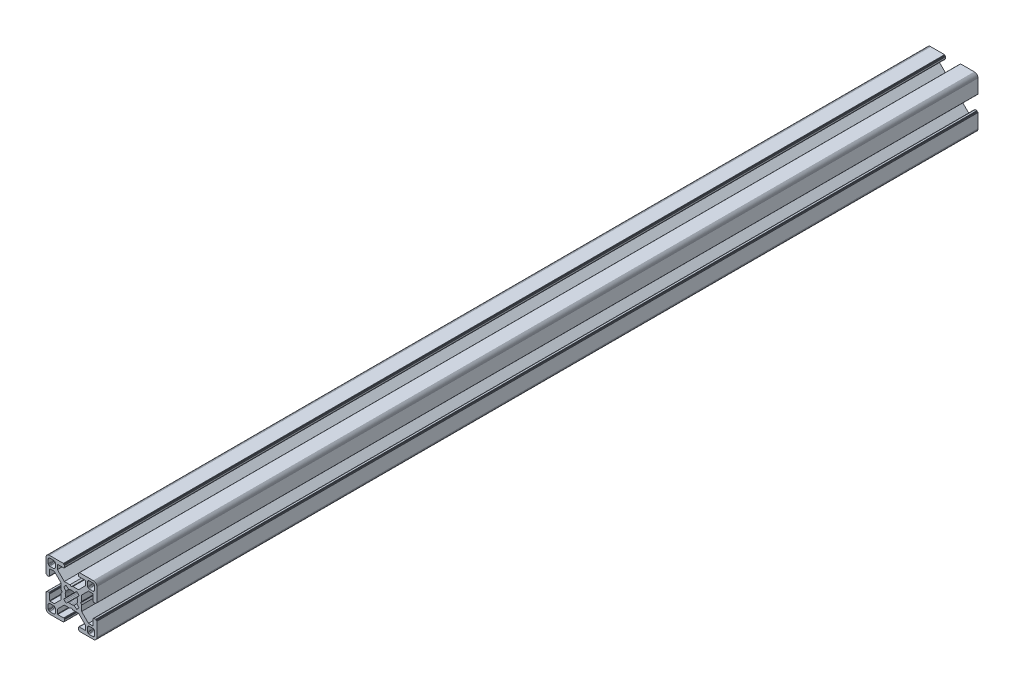
from build123d import *

# Parameters (mm, degrees)
BOSS_EXTRUDE1_DEPTH = 520


with BuildPart() as part:
    # Sketch1 → Boss-Extrude1 (new body)
    with BuildSketch(Plane.XY):
        Polygon((28.34729664, 29.969613999), (28.000000864, 29.999999329), (19.750000909, 29.999999329), (19.715268165, 29.996961355), (19.681595266, 29.987938702), (19.649999216, 29.973205179), (19.621443003, 29.953207821), (19.596790895, 29.928557575), (19.576793537, 29.899999499), (19.562061876, 29.868405312), (19.55303736, 29.834728688), (19.549999386, 29.799999669), (19.549999386, 29.699999839), (19.546961412, 29.665268958), (19.537936896, 29.631596059), (19.523203373, 29.599998146), (19.503207877, 29.571441934), (19.478557631, 29.546789825), (19.449999556, 29.526794329), (19.418403506, 29.512060806), (19.384728745, 29.503038153), (19.349999726, 29.500000179), (19.249999896, 29.500000179), (19.215267517, 29.496958527), (19.181592755, 29.487935874), (19.149996706, 29.47320235), (19.12143863, 29.453206855), (19.096788384, 29.428554746), (19.076791026, 29.399996671), (19.062057503, 29.368402484), (19.05303485, 29.334725859), (19.049996876, 29.299998703), (19.049996876, 28.39999837), (19.059110798, 28.29580945), (19.08618062, 28.194785165), (19.13038119, 28.099997016), (19.190369539, 28.014324653), (19.264324002, 27.94037019), (19.349996366, 27.88038184), (19.444784515, 27.836181271), (19.545806937, 27.809111449), (19.650010894, 27.799984574), (23.050010706, 27.799984574), (23.084741588, 27.7969466), (23.118414487, 27.787923946), (23.150012399, 27.773190423), (23.178568612, 27.753193065), (23.203220721, 27.728542819), (23.223218079, 27.699984744), (23.237949739, 27.668386831), (23.246974255, 27.634713932), (23.25001142, 27.59998608), (23.25001142, 25.049987618), (19.204474482, 20.999982084), (15.900007876, 20.999982084), (15.000008474, 20.48483404), (14.10000814, 20.999982084), (10.795543398, 20.999982084), (7.997342887, 23.801274731), (6.750011387, 25.049984589), (6.750011387, 27.599983051), (6.753049362, 27.634713932), (6.762072946, 27.668386831), (6.776805538, 27.699984744), (6.796801965, 27.728542819), (6.821454073, 27.753193065), (6.850011218, 27.773190423), (6.881607267, 27.787923946), (6.915282029, 27.7969466), (6.950011048, 27.799984574), (10.350011791, 27.799984574), (10.45420071, 27.809098497), (10.555223133, 27.836168318), (10.650011282, 27.880368888), (10.735683645, 27.940357238), (10.809638108, 28.014311701), (10.869626458, 28.099984064), (10.913827027, 28.194772213), (10.940895918, 28.295796498), (10.950010772, 28.399985417), (10.950010772, 29.299985751), (10.946974575, 29.334739239), (10.93795065, 29.368415522), (10.923215933, 29.400009153), (10.903218427, 29.428566473), (10.878566319, 29.45321765), (10.849999264, 29.473204166), (10.818403214, 29.487937689), (10.784728453, 29.496960342), (10.749999434, 29.500000179), (10.649999604, 29.500000179), (10.615270585, 29.503038153), (10.581595823, 29.512060806), (10.549999774, 29.526794329), (10.521441698, 29.546789825), (10.496791452, 29.571441934), (10.476795025, 29.599998146), (10.462061502, 29.631596059), (10.453037918, 29.665268958), (10.449999943, 29.699999839), (10.449999943, 29.799999669), (10.446961969, 29.834728688), (10.437938385, 29.868405312), (10.423205793, 29.899999499), (10.403208435, 29.928557575), (10.378557257, 29.953207821), (10.350000113, 29.973205179), (10.318404064, 29.987938702), (10.284729302, 29.996961355), (10.250000283, 29.999999329), (1.999999397, 29.999999329), (1.652702689, 29.969613999), (1.315958682, 29.879383743), (0.999999233, 29.732050374), (0.714424066, 29.532089829), (0.467910431, 29.285576195), (0.267948955, 28.999999166), (0.120614655, 28.684040532), (0.030384399, 28.34729664), (0, 28.000000864), (0, 19.750000909), (0.003037974, 19.715268165), (0.012061559, 19.681595266), (0.026795082, 19.649999216), (0.046790577, 19.621441141), (0.071442686, 19.596789032), (0.09999983, 19.576793537), (0.13159588, 19.562060013), (0.165270641, 19.55303736), (0.19999966, 19.549999386), (0.299999461, 19.549999386), (0.334728509, 19.546959549), (0.368403242, 19.537936896), (0.399999321, 19.523203373), (0.428556465, 19.503207877), (0.453208573, 19.478555769), (0.473204069, 19.449997693), (0.487937592, 19.418403506), (0.496961176, 19.384728745), (0.499999151, 19.349999726), (0.499999151, 19.249998033), (0.503038056, 19.215269014), (0.512060709, 19.181594253), (0.526794232, 19.150000066), (0.546790194, 19.121441524), (0.571441837, 19.096789882), (0.60000029, 19.076794925), (0.631595686, 19.062061999), (0.665270619, 19.053039982), (0.700000626, 19.050000801), (1.60000096, 19.050000801), (1.704189879, 19.059116587), (1.805213233, 19.086186409), (1.90000045, 19.130385115), (1.985673745, 19.190375328), (2.059627277, 19.264327928), (2.119616325, 19.350002154), (2.163816196, 19.444788441), (2.190886018, 19.545812726), (2.200000872, 19.650001645), (2.200000872, 23.050001457), (2.203039777, 23.084732338), (2.212062431, 23.118405237), (2.226795954, 23.15000315), (2.246792381, 23.178559362), (2.271443558, 23.203211471), (2.300000702, 23.223206967), (2.331596752, 23.23794049), (2.365271513, 23.246965006), (2.400001464, 23.250001117), (4.950000857, 23.250001117), (7.997332093, 20.202670812), (8.995535423, 19.204467788), (8.995535423, 15.900001182), (9.515148227, 15.00000178), (8.995535423, 14.100002378), (8.995535423, 10.795536704), (4.950000857, 6.750002138), (2.400001464, 6.750002138), (2.365271513, 6.753040112), (2.331596752, 6.762063697), (2.300000702, 6.77679722), (2.271443558, 6.796793647), (2.246792381, 6.821444824), (2.226795954, 6.850001968), (2.212062431, 6.881598018), (2.203039777, 6.915272779), (2.200000872, 6.950002729), (2.200000872, 10.350002542), (2.190896812, 10.454174265), (2.16382699, 10.555197618), (2.119627119, 10.649984836), (2.059638071, 10.735658131), (1.985684539, 10.809611663), (1.900011244, 10.869600944), (1.805224027, 10.913800582), (1.704200673, 10.940870404), (1.600011754, 10.949986189), (0.70001142, 10.949986189), (0.665281355, 10.946948596), (0.631606253, 10.937926283), (0.600010578, 10.923193954), (0.571451747, 10.903199537), (0.546799638, 10.87854836), (0.526794232, 10.850000195), (0.512060709, 10.818404146), (0.503038056, 10.784730315), (0.499999151, 10.750000365), (0.499999151, 10.650000535), (0.496961176, 10.615270585), (0.487937592, 10.581596754), (0.473204069, 10.550000705), (0.453208573, 10.521443561), (0.428556465, 10.496791452), (0.399999321, 10.476795956), (0.368403242, 10.462062433), (0.334728509, 10.453038849), (0.299999461, 10.449999943), (0.19999966, 10.449999943), (0.165270641, 10.446961969), (0.13159588, 10.437939316), (0.09999983, 10.423205793), (0.071442686, 10.403209366), (0.046790577, 10.378558189), (0.026795082, 10.350000113), (0.012061559, 10.318404064), (0.003037974, 10.284729302), (0, 10.250000283), (0, 1.999999397), (0.030384399, 1.652702689), (0.120614655, 1.315958682), (0.267948955, 0.999999233), (0.467910431, 0.714424066), (0.714424066, 0.467910431), (0.999999233, 0.267948955), (1.315958682, 0.120614655), (1.652702689, 0.030384399), (1.999999397, 0), (10.250000283, 0), (10.284729302, 0.003037974), (10.318404064, 0.012061559), (10.350000113, 0.026795082), (10.378557257, 0.046790577), (10.403208435, 0.071442686), (10.423205793, 0.09999983), (10.437938385, 0.13159588), (10.446961969, 0.165270641), (10.449999943, 0.19999966), (10.449999943, 0.300000422), (10.453037918, 0.334729441), (10.462061502, 0.368404202), (10.476795025, 0.400000252), (10.496791452, 0.428557396), (10.521441698, 0.453208573), (10.549999774, 0.473205), (10.581595823, 0.487938523), (10.615270585, 0.496961176), (10.649999604, 0.500000082), (10.749999434, 0.500000082), (10.784728453, 0.503038056), (10.818403214, 0.512060709), (10.849999264, 0.526794232), (10.878547894, 0.546800104), (10.903198606, 0.571451747), (10.923194493, 0.6000102), (10.93792742, 0.631606528), (10.946949437, 0.66528146), (10.950010772, 0.699984975), (10.950010772, 1.599985308), (10.940895918, 1.704174228), (10.913827027, 1.805197581), (10.869626458, 1.89998573), (10.809638108, 1.985658094), (10.735683645, 2.059612557), (10.650011282, 2.119600674), (10.555223133, 2.163801476), (10.45420071, 2.190870367), (10.350011791, 2.199985221), (6.950011048, 2.199985221), (6.915282029, 2.203024126), (6.881607267, 2.212046779), (6.850011218, 2.226780302), (6.821454073, 2.246776729), (6.796801965, 2.271427907), (6.776805538, 2.299985982), (6.762072946, 2.331582032), (6.753049362, 2.365256793), (6.750011387, 2.399985812), (6.750011387, 4.949985206), (9.787457566, 7.990785077), (10.795545277, 8.999985833), (14.100010019, 8.999985833), (15.000010353, 9.515133877), (15.900009756, 8.999985833), (19.204476361, 8.999985833), (20.21256413, 7.990786065), (23.25001142, 4.949988235), (23.25001142, 2.399988841), (23.246974255, 2.365256793), (23.237949739, 2.331582032), (23.223218079, 2.299985982), (23.203220721, 2.271427907), (23.178568612, 2.246776729), (23.150012399, 2.226780302), (23.118414487, 2.212046779), (23.084741588, 2.203024126), (23.050010706, 2.199985221), (19.650010894, 2.199985221), (19.545806937, 2.190883319), (19.444784515, 2.163814428), (19.349996366, 2.119613626), (19.264324002, 2.059625509), (19.190369539, 1.985671046), (19.13038119, 1.899998682), (19.08618062, 1.805210533), (19.059110798, 1.70418718), (19.049996876, 1.599998261), (19.049996876, 0.699997927), (19.053035506, 0.665268966), (19.062058795, 0.631594374), (19.076792915, 0.599998603), (19.096790813, 0.571440905), (19.121441524, 0.546790194), (19.149999978, 0.526794306), (19.181596306, 0.51206138), (19.215271238, 0.503039363), (19.249999896, 0.500000082), (19.349999726, 0.500000082), (19.384728745, 0.496961176), (19.418403506, 0.487938523), (19.449999556, 0.473205), (19.478557631, 0.453208573), (19.503207877, 0.428557396), (19.523203373, 0.400000252), (19.537936896, 0.368404202), (19.546961412, 0.334729441), (19.549999386, 0.300000422), (19.549999386, 0.19999966), (19.55303736, 0.165270641), (19.562061876, 0.13159588), (19.576793537, 0.09999983), (19.596789964, 0.071441755), (19.621442072, 0.046789646), (19.649998285, 0.02679415), (19.681594335, 0.012060627), (19.715267234, 0.003037043), (19.750000909, 0), (28.000000864, 0), (28.34729664, 0.030384399), (28.684040532, 0.120614655), (28.999999166, 0.267948955), (29.285576195, 0.467910431), (29.532089829, 0.714424066), (29.732050374, 0.999999233), (29.879383743, 1.315958682), (29.969613999, 1.652702689), (29.999999329, 1.999999397), (29.999999329, 10.250000283), (29.996974806, 10.284715361), (29.987951516, 10.318389952), (29.973217396, 10.349985723), (29.953219499, 10.378543421), (29.928568787, 10.403194133), (29.899999499, 10.423205793), (29.868405312, 10.437939316), (29.834728688, 10.446961969), (29.799999669, 10.449999943), (29.699999839, 10.449999943), (29.664909937, 10.453400043), (29.631233313, 10.462423628), (29.599637263, 10.477157151), (29.57108105, 10.497152646), (29.546427079, 10.521804755), (29.526433446, 10.550361899), (29.511699923, 10.581957949), (29.502675407, 10.615631779), (29.499637433, 10.650361729), (29.499637433, 10.750361559), (29.49697202, 10.784715548), (29.487949367, 10.818389378), (29.473215844, 10.849985428), (29.453220348, 10.878542572), (29.428568239, 10.90319468), (29.400010164, 10.923190176), (29.368415977, 10.937923699), (29.334741215, 10.946947284), (29.300012197, 10.949986189), (28.400011863, 10.949986189), (28.29581215, 10.9408876), (28.194787865, 10.913817778), (28.099999716, 10.86961814), (28.014327352, 10.809628859), (27.940374752, 10.735675327), (27.880384539, 10.650002032), (27.836185833, 10.555214814), (27.809114148, 10.454191461), (27.800000225, 10.350002542), (27.800000225, 6.950002729), (27.796962251, 6.915272779), (27.787939598, 6.881598018), (27.773206075, 6.850001968), (27.753208716, 6.821444824), (27.728558471, 6.796793647), (27.700000395, 6.77679722), (27.668404345, 6.762063697), (27.634729584, 6.753040112), (27.599998702, 6.750002138), (25.05000024, 6.750002138), (23.809199132, 7.99080223), (21.004464477, 10.795534588), (21.004464477, 14.100000262), (20.484851673, 14.999999665), (21.004464477, 15.899999067), (21.004464477, 19.204465672), (25.05000024, 23.250001117), (27.599998702, 23.250001117), (27.634729584, 23.246965006), (27.668404345, 23.23794049), (27.700000395, 23.223206967), (27.728558471, 23.203211471), (27.753208716, 23.178559362), (27.773206075, 23.15000315), (27.787939598, 23.118405237), (27.796962251, 23.084732338), (27.800000225, 23.050001457), (27.800000225, 19.650001645), (27.809114148, 19.545812726), (27.836185833, 19.444788441), (27.880384539, 19.350002154), (27.940370508, 19.264323684), (28.014323108, 19.190371084), (28.099995472, 19.130380872), (28.194783621, 19.086182165), (28.295807906, 19.059112343), (28.400001069, 19.050000801), (29.300001402, 19.050000801), (29.334730421, 19.053040638), (29.368405183, 19.062063291), (29.39999937, 19.076796814), (29.42819671, 19.097149726), (29.452848353, 19.1218023), (29.472843309, 19.150360754), (29.487576235, 19.181955219), (29.496598252, 19.215630151), (29.499637433, 19.250359227), (29.499637433, 19.35036092), (29.502675407, 19.385089939), (29.511699923, 19.4187647), (29.526433446, 19.450358887), (29.546427079, 19.478916963), (29.57108105, 19.503569071), (29.599637263, 19.523564567), (29.631233313, 19.53829809), (29.664909937, 19.547320743), (29.699999839, 19.549999386), (29.799999669, 19.549999386), (29.834728688, 19.55303736), (29.868405312, 19.562060013), (29.899999499, 19.576793537), (29.928557575, 19.596789032), (29.953207821, 19.621441141), (29.973205179, 19.649999216), (29.987938702, 19.681595266), (29.996961355, 19.715268165), (29.999999329, 19.750000909), (29.999999329, 28.000000864), (29.969613999, 28.34729664), (29.879383743, 28.684040532), (29.732050374, 28.999999166), (29.532089829, 29.285576195), (29.285576195, 29.532089829), (28.999999166, 29.732050374), (28.684040532, 29.879383743), align=None)
        Polygon((1.299998723, 25.499999523), (1.299998723, 27.699999511), (1.312309876, 27.856435627), (1.348942518, 28.009016067), (1.408992335, 28.153989464), (1.490981318, 28.287785128), (1.592892222, 28.407108039), (1.71221327, 28.50901708), (1.846008119, 28.591006994), (1.9909814, 28.651056811), (2.143563703, 28.687689453), (2.299998887, 28.699999675), (4.499998875, 28.699999675), (4.656434059, 28.687689453), (4.809016362, 28.651056811), (4.953989759, 28.591006994), (5.087784491, 28.50901708), (5.207106471, 28.407108039), (5.309016444, 28.287785128), (5.391005427, 28.153989464), (5.451056175, 28.009016067), (5.487687886, 27.856435627), (5.499999039, 27.699999511), (5.499999039, 25.499999523), (5.487687886, 25.34356527), (5.451056175, 25.190982968), (5.391005427, 25.04600957), (5.309016444, 24.912213907), (5.207106471, 24.792892858), (5.087784491, 24.690981954), (4.953989759, 24.60899204), (4.809016362, 24.548944086), (4.656434059, 24.512309581), (4.499998875, 24.499999359), (2.299998887, 24.499999359), (2.143563703, 24.512309581), (1.9909814, 24.548944086), (1.846008119, 24.60899204), (1.71221327, 24.690981954), (1.592892222, 24.792892858), (1.490981318, 24.912213907), (1.408992335, 25.04600957), (1.348942518, 25.190982968), (1.312309876, 25.34356527), align=None, mode=Mode.SUBTRACT)
        Polygon((25.34356527, 28.687689453), (25.499999523, 28.699999675), (27.699999511, 28.699999675), (27.856435627, 28.687689453), (28.009017929, 28.651056811), (28.153991327, 28.591006994), (28.28778699, 28.50901708), (28.407108039, 28.407108039), (28.50901708, 28.287785128), (28.591006994, 28.153989464), (28.651056811, 28.009016067), (28.687689453, 27.856435627), (28.700001538, 27.699999511), (28.700001538, 25.499999523), (28.687689453, 25.34356527), (28.651056811, 25.190982968), (28.591006994, 25.04600957), (28.50901708, 24.912213907), (28.407108039, 24.792892858), (28.28778699, 24.690981954), (28.153991327, 24.60899204), (28.009017929, 24.548944086), (27.856435627, 24.512309581), (27.699999511, 24.499999359), (25.499999523, 24.499999359), (25.34356527, 24.512309581), (25.190982968, 24.548944086), (25.04600957, 24.60899204), (24.912215769, 24.690981954), (24.792892858, 24.792892858), (24.690981954, 24.912213907), (24.608993903, 25.04600957), (24.548944086, 25.190982968), (24.512311444, 25.34356527), (24.500001222, 25.499999523), (24.500001222, 27.699999511), (24.512311444, 27.856435627), (24.548944086, 28.009016067), (24.608993903, 28.153989464), (24.690981954, 28.287785128), (24.792892858, 28.407108039), (24.912215769, 28.50901708), (25.04600957, 28.591006994), (25.190982968, 28.651056811), align=None, mode=Mode.SUBTRACT)
        Polygon((14.999999665, 18.649999052), (15.550030395, 18.608318642), (16.087498516, 18.484227359), (16.600128263, 18.280562013), (18.13592948, 19.518401474), (18.644984812, 19.11874488), (19.103571773, 18.662061542), (19.505336881, 18.154669553), (18.280562013, 16.600130126), (18.484227359, 16.087498516), (18.608318642, 15.550030395), (18.649999052, 14.999999665), (18.608318642, 14.449968934), (18.484227359, 13.912500814), (18.280562013, 13.399870135), (19.505336881, 11.845329776), (19.103571773, 11.337937787), (18.644984812, 10.881252587), (18.13592948, 10.481598787), (16.600128263, 11.719437316), (16.087498516, 11.515771039), (15.550030395, 11.391680688), (14.999999665, 11.349999346), (14.449968934, 11.391680688), (13.912500814, 11.515771039), (13.399870135, 11.719437316), (11.864069849, 10.481598787), (11.355013587, 10.881252587), (10.896427557, 11.337937787), (10.494662449, 11.845329776), (11.719438247, 13.399870135), (11.515771039, 13.912500814), (11.391680688, 14.449968934), (11.349999346, 14.999999665), (11.391680688, 15.550030395), (11.515771039, 16.087498516), (11.719438247, 16.600130126), (10.494662449, 18.154669553), (10.896427557, 18.662061542), (11.355013587, 19.11874488), (11.864069849, 19.518401474), (13.399870135, 18.280562013), (13.912500814, 18.484227359), (14.449968934, 18.608318642), align=None, mode=Mode.SUBTRACT)
        Polygon((4.499998875, 1.299999771), (2.299998887, 1.299999771), (2.143563703, 1.312310807), (1.9909814, 1.348942518), (1.846008119, 1.408992335), (1.71221327, 1.490982249), (1.592892222, 1.592892222), (1.490981318, 1.712214202), (1.408992335, 1.846008934), (1.348942518, 1.990982331), (1.312309876, 2.143564634), (1.299998723, 2.299998887), (1.299998723, 4.499999806), (1.312309876, 4.656434059), (1.348942518, 4.809017293), (1.408992335, 4.95399069), (1.490981318, 5.087785423), (1.592892222, 5.207106471), (1.71221327, 5.309017375), (1.846008119, 5.391006358), (1.9909814, 5.451056175), (2.143563703, 5.487688817), (2.299998887, 5.49999997), (4.499998875, 5.49999997), (4.656434059, 5.487688817), (4.809016362, 5.451056175), (4.953989759, 5.391006358), (5.087784491, 5.309017375), (5.207106471, 5.207106471), (5.309016444, 5.087785423), (5.391005427, 4.95399069), (5.451056175, 4.809017293), (5.487687886, 4.656434059), (5.499999039, 4.499999806), (5.499999039, 2.299998887), (5.487687886, 2.143564634), (5.451056175, 1.990982331), (5.391005427, 1.846008934), (5.309016444, 1.712214202), (5.207106471, 1.592892222), (5.087784491, 1.490982249), (4.953989759, 1.408992335), (4.809016362, 1.348942518), (4.656434059, 1.312310807), align=None, mode=Mode.SUBTRACT)
        Polygon((27.699999511, 1.299999771), (25.499999523, 1.299999771), (25.34356527, 1.312310807), (25.190982968, 1.348942518), (25.04600957, 1.408992335), (24.912215769, 1.490982249), (24.792892858, 1.592892222), (24.690981954, 1.712214202), (24.608993903, 1.846008934), (24.548944086, 1.990982331), (24.512311444, 2.143564634), (24.500001222, 2.299998887), (24.500001222, 4.499999806), (24.512311444, 4.656434059), (24.548944086, 4.809017293), (24.608993903, 4.95399069), (24.690981954, 5.087785423), (24.792892858, 5.207106471), (24.912215769, 5.309017375), (25.04600957, 5.391006358), (25.190982968, 5.451056175), (25.34356527, 5.487688817), (25.499999523, 5.49999997), (27.699999511, 5.49999997), (27.856435627, 5.487688817), (28.009017929, 5.451056175), (28.153991327, 5.391006358), (28.28778699, 5.309017375), (28.407108039, 5.207106471), (28.50901708, 5.087785423), (28.591006994, 4.95399069), (28.651056811, 4.809017293), (28.687689453, 4.656434059), (28.700001538, 4.499999806), (28.700001538, 2.299998887), (28.687689453, 2.143564634), (28.651056811, 1.990982331), (28.591006994, 1.846008934), (28.50901708, 1.712214202), (28.407108039, 1.592892222), (28.28778699, 1.490982249), (28.153991327, 1.408992335), (28.009017929, 1.348942518), (27.856435627, 1.312310807), align=None, mode=Mode.SUBTRACT)
    extrude(amount=-BOSS_EXTRUDE1_DEPTH)


solid = part.part
